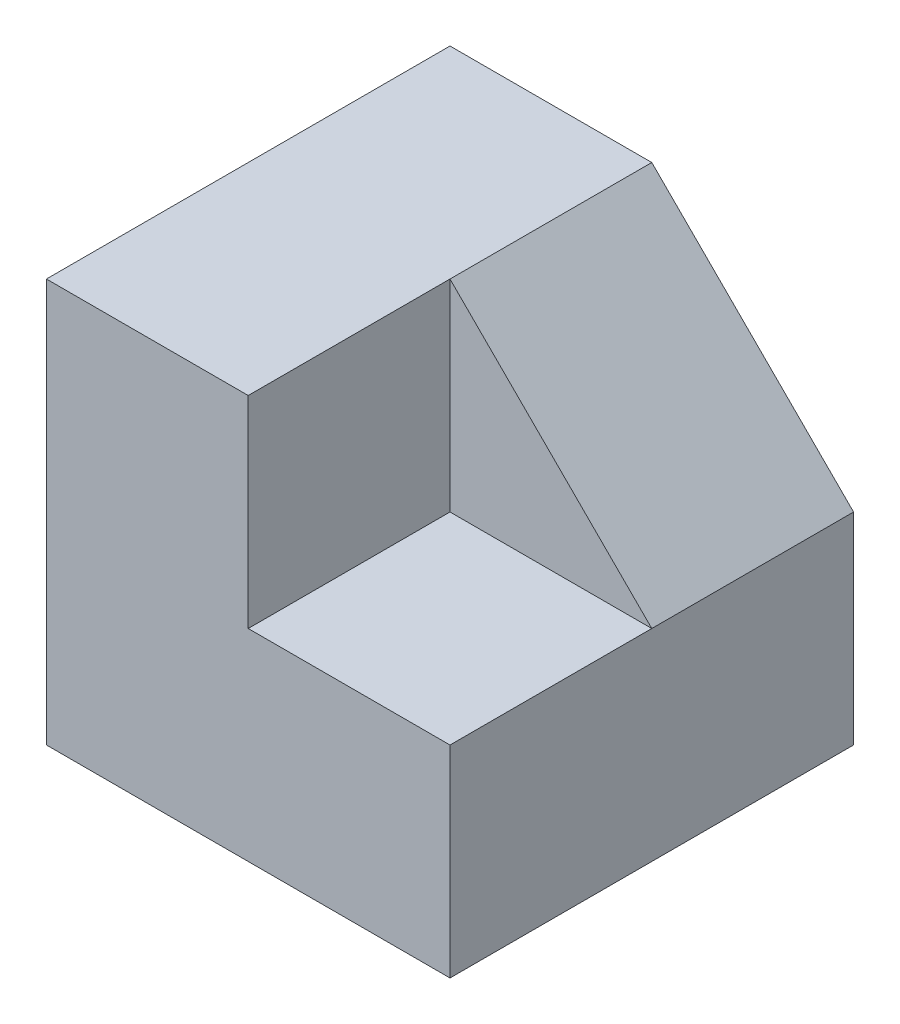
from build123d import *

# Parameters (mm, degrees)
CROQUIS1_W              = 60
CROQUIS1_H              = 60
SALIENTE_EXTRUIR1_DEPTH = 60
CROQUIS2_W              = 30
CROQUIS2_H              = 30
CORTAR_EXTRUIR1_DEPTH   = 30
CORTAR_EXTRUIR2_DEPTH   = 30


with BuildPart() as part:
    # Croquis1 → Saliente-Extruir1 (new body)
    with BuildSketch(Plane(origin=(0, 0, 0), x_dir=(1, 0, 0), z_dir=(0, 1, 0))):
        with Locations((30, -30)):
            Rectangle(CROQUIS1_W, CROQUIS1_H)
    extrude(amount=SALIENTE_EXTRUIR1_DEPTH)

    # Croquis2 → Cortar-Extruir1 (cut)
    with BuildSketch(Plane(origin=(0, 60, 0), x_dir=(1, 0, 0), z_dir=(0, 1, 0))):
        with Locations((45, -45)):
            Rectangle(CROQUIS2_W, CROQUIS2_H)
    extrude(amount=-CORTAR_EXTRUIR1_DEPTH, mode=Mode.SUBTRACT)

    # Croquis3 → Cortar-Extruir2 (cut)
    with BuildSketch(Plane.XY.offset(30)):
        Polygon((30, 60), (60, 30), (60, 60), align=None)
    extrude(amount=-CORTAR_EXTRUIR2_DEPTH, mode=Mode.SUBTRACT)


solid = part.part
